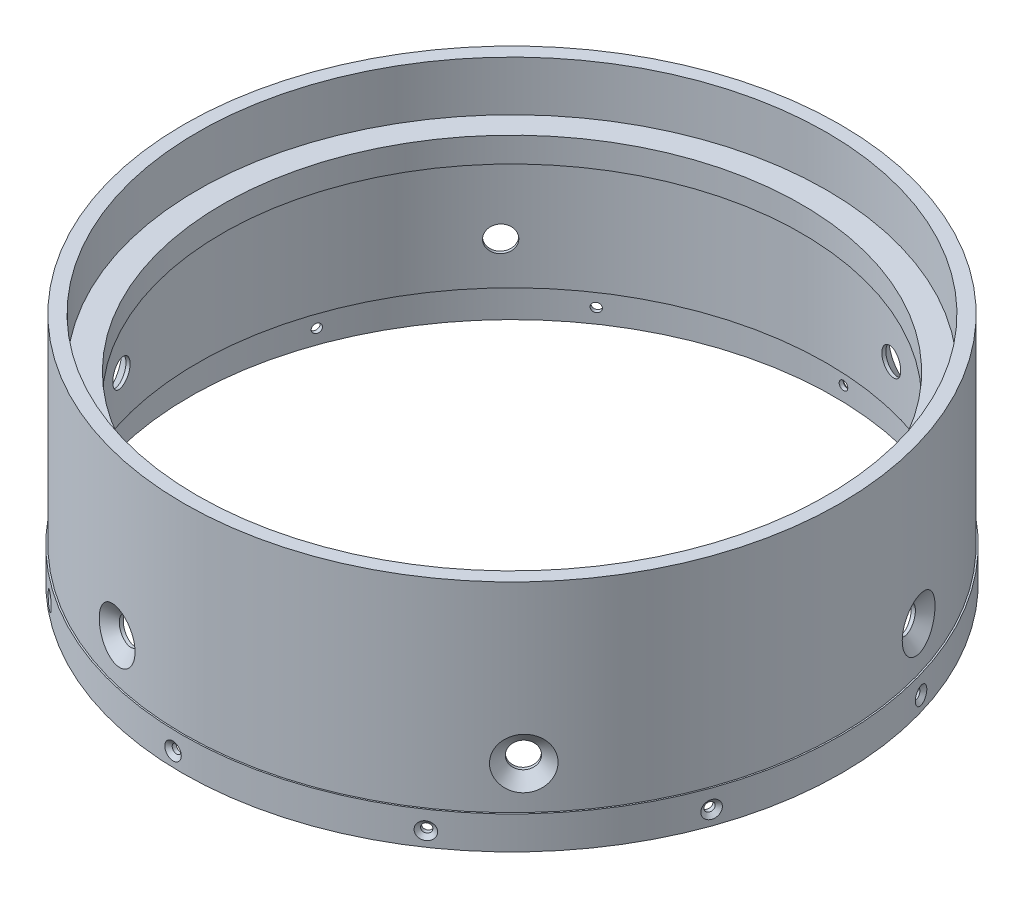
from build123d import *

# Parameters (mm, degrees)
CIRPATTERN1_COUNT = 10
CIRPATTERN2_COUNT = 6


with BuildPart() as part:
    # Sketch2 → Revolve1 (revolve)
    with BuildSketch(Plane(origin=(0, 0, 0), x_dir=(0, 0, -1), z_dir=(1, 0, 0))):
        Polygon((79.99222, 10.507544326), (83.439, 10.507544326), (83.439, -40.292455674), (83.82, -40.292455674), (83.82, -48.674455674), (81.9531, -48.674455674), (81.9531, -40.292455674), (79.99222, -40.292455674), (79.99222, -8.542455674), (73.64222, -8.542455674), (73.64222, -2.192455674), (79.99222, -2.192455674), align=None)
    revolve(axis=Axis((0, 0, 0), (0, -1, 0)))

    # Sketch3 → CSK for #2 Flat Head Machine Screw (100)1 (revolve, cut)
    with BuildSketch(Plane(origin=(2.413258622, -45.008517513, -83.785252777), x_dir=(-0.999585454, 0, -0.028790964), z_dir=(0, 1, 0))):
        Polygon((0, 0), (0, 76.879152758), (1.1303, 76.2), (1.1303, 0.884494921), (2.1844, 0), align=None)
    csk_for_2_flat_head_machine_screw_100 = revolve(axis=Axis((2.596081245, -45.008517513, -90.132620411), (-0.028790964, 0, 0.999585454)), mode=Mode.SUBTRACT)

    # CirPattern1: CSK for #2 Flat Head Machine Screw (100)1 ×10 about axis
    cirpattern1_axis = Axis((0, 0, 0), (0, 1, 0))
    for i in range(1, CIRPATTERN1_COUNT):
        add(csk_for_2_flat_head_machine_screw_100.rotate(cirpattern1_axis, i * 360 / CIRPATTERN1_COUNT), mode=Mode.SUBTRACT)

    # Sketch4 → CSK for 1/4 Flat Head Machine Screw (100)1 (revolve, cut)
    with BuildSketch(Plane(origin=(80.020293691, -29.487820217, -23.639359524), x_dir=(-0.283313073, 0, -0.959027477), z_dir=(0, 1, 0))):
        Polygon((0, 0), (0, 27.361148974), (3.2639, 25.4), (3.2639, 2.664141329), (6.4389, 0), align=None)
    csk_for_1_4_flat_head_machine_screw_100 = revolve(axis=Axis((86.110118172, -29.487820217, -25.438397539), (-0.959027477, 0, 0.283313073)), mode=Mode.SUBTRACT)

    # CirPattern2: CSK for 1/4 Flat Head Machine Screw (100)1 ×6 about axis
    cirpattern2_axis = Axis((0, 0, 0), (0, 1, 0))
    for i in range(1, CIRPATTERN2_COUNT):
        add(csk_for_1_4_flat_head_machine_screw_100.rotate(cirpattern2_axis, i * 360 / CIRPATTERN2_COUNT), mode=Mode.SUBTRACT)


solid = part.part
